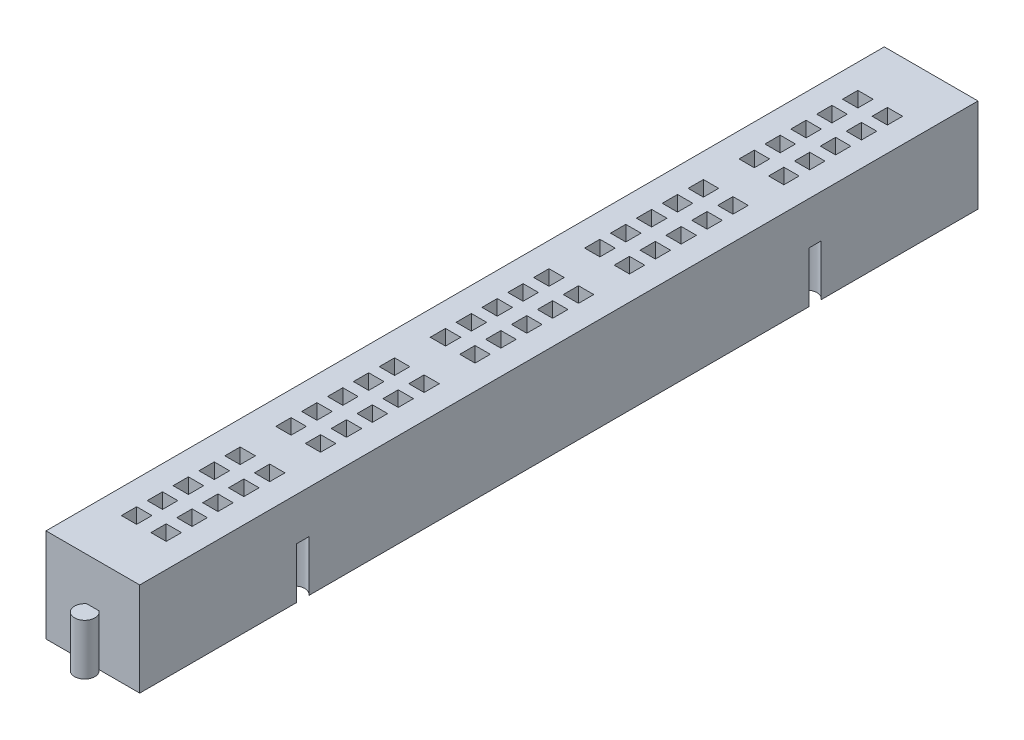
from build123d import *

# Parameters (mm, degrees)
SKETCH1_W           = 9.2
SKETCH1_H           = 82.3
BOSS_EXTRUDE1_DEPTH = 9.2
SKETCH2_W           = 1.5
SKETCH2_H           = 1.5
CUT_EXTRUDE1_DEPTH  = 8
SKETCH3_R           = 1
BOSS_EXTRUDE2_DEPTH = 5
SKETCH3_3_R         = 1
CUT_EXTRUDE2_DEPTH  = 5


with BuildPart() as part:
    # Sketch1 → Boss-Extrude1 (new body)
    with BuildSketch(Plane(origin=(0, 0, 0), x_dir=(1, 0, 0), z_dir=(0, 1, 0))):
        with Locations((-1.983526012, 2.140751445)):
            Rectangle(SKETCH1_W, SKETCH1_H)
    extrude(amount=BOSS_EXTRUDE1_DEPTH)

    # Sketch2 → Cut-Extrude1 (cut)
    with BuildSketch(Plane(origin=(0, 9.2, 0), x_dir=(1, 0, 0), z_dir=(0, 1, 0))):
        with Locations((-3.433526012, 37.540751445)):
            Rectangle(SKETCH2_W, SKETCH2_H)
        with Locations((-0.533526012, 37.540751445)):
            Rectangle(SKETCH2_W, SKETCH2_H)
        with Locations((-3.433526012, 35.000751445)):
            Rectangle(SKETCH2_W, SKETCH2_H)
        with Locations((-0.533526012, 35.000751445)):
            Rectangle(SKETCH2_W, SKETCH2_H)
        with Locations((-3.433526012, 32.460751445)):
            Rectangle(SKETCH2_W, SKETCH2_H)
        with Locations((-0.533526012, 32.460751445)):
            Rectangle(SKETCH2_W, SKETCH2_H)
        with Locations((-3.433526012, 29.920751445)):
            Rectangle(SKETCH2_W, SKETCH2_H)
        with Locations((-0.533526012, 29.920751445)):
            Rectangle(SKETCH2_W, SKETCH2_H)
        with Locations((-3.433526012, 27.380751445)):
            Rectangle(SKETCH2_W, SKETCH2_H)
        with Locations((-0.533526012, 27.380751445)):
            Rectangle(SKETCH2_W, SKETCH2_H)
        with Locations((-3.433526012, 22.380751445)):
            Rectangle(SKETCH2_W, SKETCH2_H)
        with Locations((-0.533526012, 22.380751445)):
            Rectangle(SKETCH2_W, SKETCH2_H)
        with Locations((-0.533526012, 19.840751445)):
            Rectangle(SKETCH2_W, SKETCH2_H)
        with Locations((-3.433526012, 19.840751445)):
            Rectangle(SKETCH2_W, SKETCH2_H)
        with Locations((-3.433526012, 17.300751445)):
            Rectangle(SKETCH2_W, SKETCH2_H)
        with Locations((-0.533526012, 17.300751445)):
            Rectangle(SKETCH2_W, SKETCH2_H)
        with Locations((-0.533526012, 14.760751445)):
            Rectangle(SKETCH2_W, SKETCH2_H)
        with Locations((-3.433526012, 14.760751445)):
            Rectangle(SKETCH2_W, SKETCH2_H)
        with Locations((-3.433526012, 12.220751445)):
            Rectangle(SKETCH2_W, SKETCH2_H)
        with Locations((-0.533526012, 12.220751445)):
            Rectangle(SKETCH2_W, SKETCH2_H)
        with Locations((-3.433526012, 7.220751445)):
            Rectangle(SKETCH2_W, SKETCH2_H)
        with Locations((-0.533526012, 7.220751445)):
            Rectangle(SKETCH2_W, SKETCH2_H)
        with Locations((-0.533526012, 4.680751445)):
            Rectangle(SKETCH2_W, SKETCH2_H)
        with Locations((-3.433526012, 4.680751445)):
            Rectangle(SKETCH2_W, SKETCH2_H)
        with Locations((-3.433526012, 2.140751445)):
            Rectangle(SKETCH2_W, SKETCH2_H)
        with Locations((-0.533526012, 2.140751445)):
            Rectangle(SKETCH2_W, SKETCH2_H)
        with Locations((-0.533526012, -0.399248555)):
            Rectangle(SKETCH2_W, SKETCH2_H)
        with Locations((-3.433526012, -0.399248555)):
            Rectangle(SKETCH2_W, SKETCH2_H)
        with Locations((-3.433526012, -2.939248555)):
            Rectangle(SKETCH2_W, SKETCH2_H)
        with Locations((-0.533526012, -2.939248555)):
            Rectangle(SKETCH2_W, SKETCH2_H)
        with Locations((-3.433526012, -7.939248555)):
            Rectangle(SKETCH2_W, SKETCH2_H)
        with Locations((-0.533526012, -7.939248555)):
            Rectangle(SKETCH2_W, SKETCH2_H)
        with Locations((-0.533526012, -10.479248555)):
            Rectangle(SKETCH2_W, SKETCH2_H)
        with Locations((-3.433526012, -10.479248555)):
            Rectangle(SKETCH2_W, SKETCH2_H)
        with Locations((-3.433526012, -13.019248555)):
            Rectangle(SKETCH2_W, SKETCH2_H)
        with Locations((-0.533526012, -13.019248555)):
            Rectangle(SKETCH2_W, SKETCH2_H)
        with Locations((-0.533526012, -15.559248555)):
            Rectangle(SKETCH2_W, SKETCH2_H)
        with Locations((-3.433526012, -15.559248555)):
            Rectangle(SKETCH2_W, SKETCH2_H)
        with Locations((-3.433526012, -18.099248555)):
            Rectangle(SKETCH2_W, SKETCH2_H)
        with Locations((-0.533526012, -18.099248555)):
            Rectangle(SKETCH2_W, SKETCH2_H)
        with Locations((-3.433526012, -23.099248555)):
            Rectangle(SKETCH2_W, SKETCH2_H)
        with Locations((-0.533526012, -23.099248555)):
            Rectangle(SKETCH2_W, SKETCH2_H)
        with Locations((-0.533526012, -25.639248555)):
            Rectangle(SKETCH2_W, SKETCH2_H)
        with Locations((-3.433526012, -25.639248555)):
            Rectangle(SKETCH2_W, SKETCH2_H)
        with Locations((-3.433526012, -28.179248555)):
            Rectangle(SKETCH2_W, SKETCH2_H)
        with Locations((-0.533526012, -28.179248555)):
            Rectangle(SKETCH2_W, SKETCH2_H)
        with Locations((-0.533526012, -30.719248555)):
            Rectangle(SKETCH2_W, SKETCH2_H)
        with Locations((-3.433526012, -30.719248555)):
            Rectangle(SKETCH2_W, SKETCH2_H)
        with Locations((-3.433526012, -33.259248555)):
            Rectangle(SKETCH2_W, SKETCH2_H)
        with Locations((-0.533526012, -33.259248555)):
            Rectangle(SKETCH2_W, SKETCH2_H)
    extrude(amount=-CUT_EXTRUDE1_DEPTH, mode=Mode.SUBTRACT)

    # Sketch3 → Boss-Extrude2 (add)
    with BuildSketch(Plane.XZ):
        with Locations((-7.383526012, -27.290751445)):
            Circle(SKETCH3_R)
        with Locations((-7.383526012, 23.009248555)):
            Circle(SKETCH3_R)
        with Locations((-1.983526012, 39.809248555)):
            Circle(SKETCH3_R)
    extrude(amount=-BOSS_EXTRUDE2_DEPTH)

    # Sketch3_3 → Cut-Extrude2 (cut)
    with BuildSketch(Plane.XZ):
        with Locations((1.816473988, 23.009248555)):
            Circle(SKETCH3_3_R)
        with Locations((1.816473988, -27.290751445)):
            Circle(SKETCH3_3_R)
        with Locations((-1.983526012, -42.490751445)):
            Circle(SKETCH3_3_R)
    extrude(amount=-CUT_EXTRUDE2_DEPTH, mode=Mode.SUBTRACT)


solid = part.part
